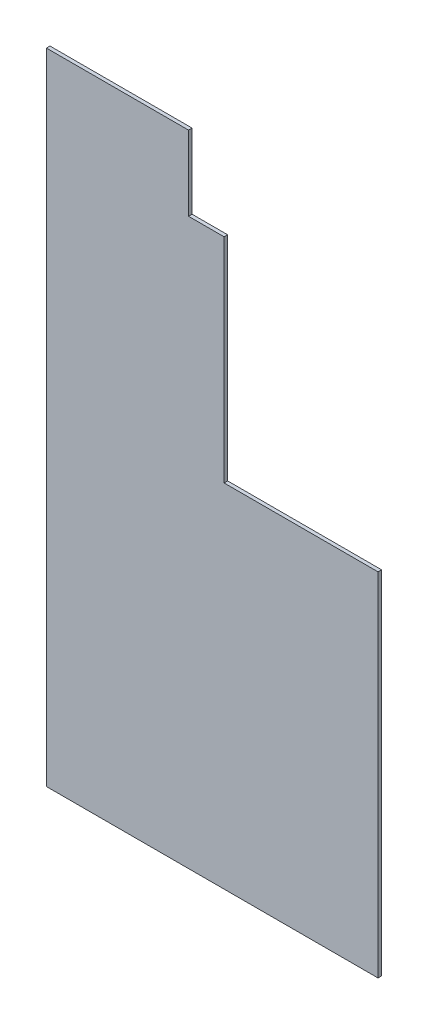
from build123d import *

# Parameters (mm, degrees)
BOSS_EXTRU_1_DEPTH = 3


with BuildPart() as part:
    # Esquisse1 → Boss.-Extru.1 (new body)
    with BuildSketch(Plane.XY):
        Polygon((228.461101291, -156.186500922), (228.461101291, -453.186500922), (-51.538898709, -453.186500922), (-51.538898709, 86.813499078), (68.461101291, 86.813499078), (68.461101291, 23.813499078), (98.461101291, 23.813499078), (98.461101291, -156.186500922), align=None)
    extrude(amount=BOSS_EXTRU_1_DEPTH)


solid = part.part
